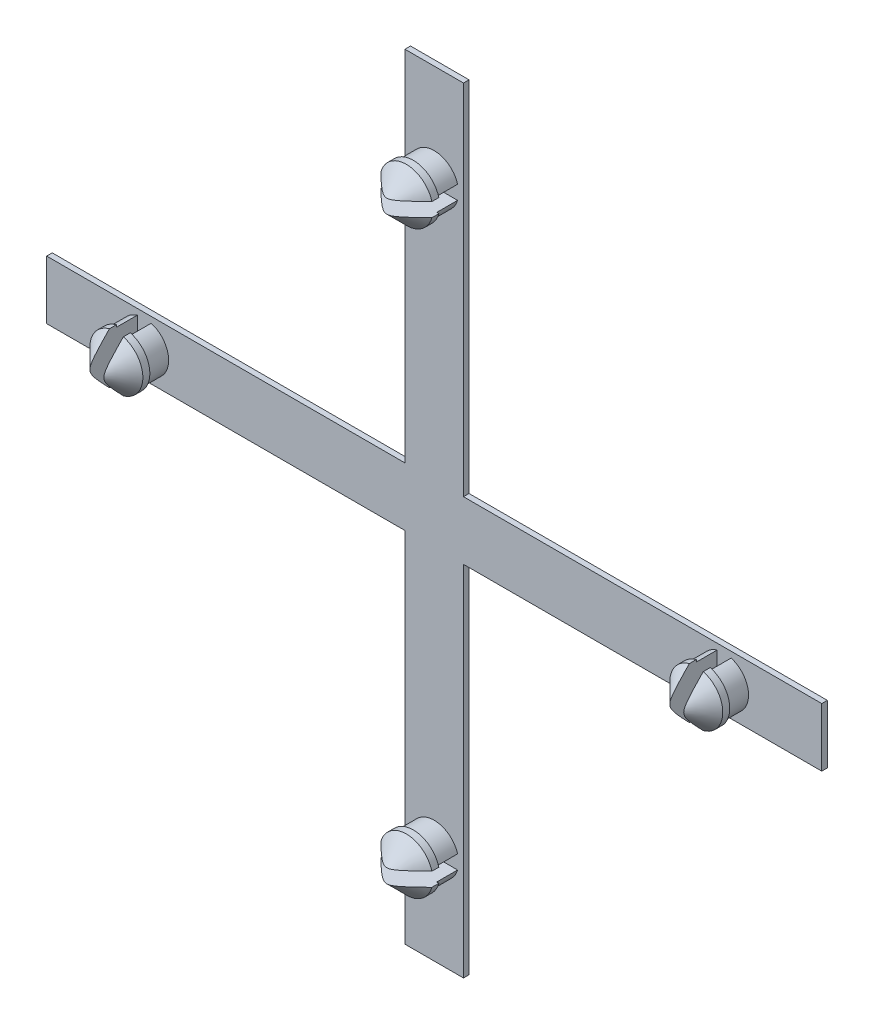
from build123d import *

# Parameters (mm, degrees)
SKICA2_W                 = 4.2
SKICA2_H                 = 55.6
SKICA2_W_2               = 55.6
SKICA2_H_2               = 4.2
P_IDAT_VYSUNUT_M2_DEPTH  = 0.4
SKICA3_R                 = 1.75
P_IDAT_VYSUNUT_M3_DEPTH  = 1.5
SKICA5_R                 = 1.9
P_IDAT_VYSUNUT_M5_DEPTH  = 2
ZKOSEN_2_SIZE            = 1.5
SKICA7_W                 = 1
SKICA7_H                 = 5
SKICA7_W_2               = 5
SKICA7_H_2               = 1
ODEBRAT_VYSUNUT_M1_DEPTH = 3.5


with BuildPart() as part:
    # Skica2 → Přidat vysunutím2 (new body)
    with BuildSketch(Plane.XY):
        Rectangle(SKICA2_W, SKICA2_H)
        Rectangle(SKICA2_W_2, SKICA2_H_2)
    extrude(amount=P_IDAT_VYSUNUT_M2_DEPTH)

    # Skica3 → Přidat vysunutím3 (add)
    with BuildSketch(Plane.XY.offset(0.4)):
        with Locations((-20.8, 0)):
            Circle(SKICA3_R)
        with Locations((0, 20.8)):
            Circle(SKICA3_R)
        with Locations((20.8, 0)):
            Circle(SKICA3_R)
        with Locations((0, -20.8)):
            Circle(SKICA3_R)
    extrude(amount=P_IDAT_VYSUNUT_M3_DEPTH)

    # Skica5 → Přidat vysunutím5 (add)
    with BuildSketch(Plane.XY.offset(1.9)):
        with Locations((-20.8, 0)):
            Circle(SKICA5_R)
        with Locations((20.8, 0)):
            Circle(SKICA5_R)
        with Locations((0, 20.8)):
            Circle(SKICA5_R)
        with Locations((0, -20.8)):
            Circle(SKICA5_R)
    extrude(amount=P_IDAT_VYSUNUT_M5_DEPTH)

    # Zkosení2
    zkosen_2_edges = [part.edges().sort_by_distance(p)[0] for p in [
        (-1.9, 20.8, 3.9),
        (-22.7, 0, 3.9),
        (18.9, 0, 3.9),
        (-1.9, -20.8, 3.9),
    ]]
    chamfer(zkosen_2_edges, length=ZKOSEN_2_SIZE)

    # Skica7 → Odebrat vysunutím1 (cut)
    with BuildSketch(Plane.XY.offset(3.9)):
        with Locations((-20.8, 0)):
            Rectangle(SKICA7_W, SKICA7_H)
        with Locations((20.8, 0)):
            Rectangle(SKICA7_W, SKICA7_H)
        with Locations((0, -20.8)):
            Rectangle(SKICA7_W_2, SKICA7_H_2)
        with Locations((0, 20.8)):
            Rectangle(SKICA7_W_2, SKICA7_H_2)
    extrude(amount=-ODEBRAT_VYSUNUT_M1_DEPTH, mode=Mode.SUBTRACT)


solid = part.part
